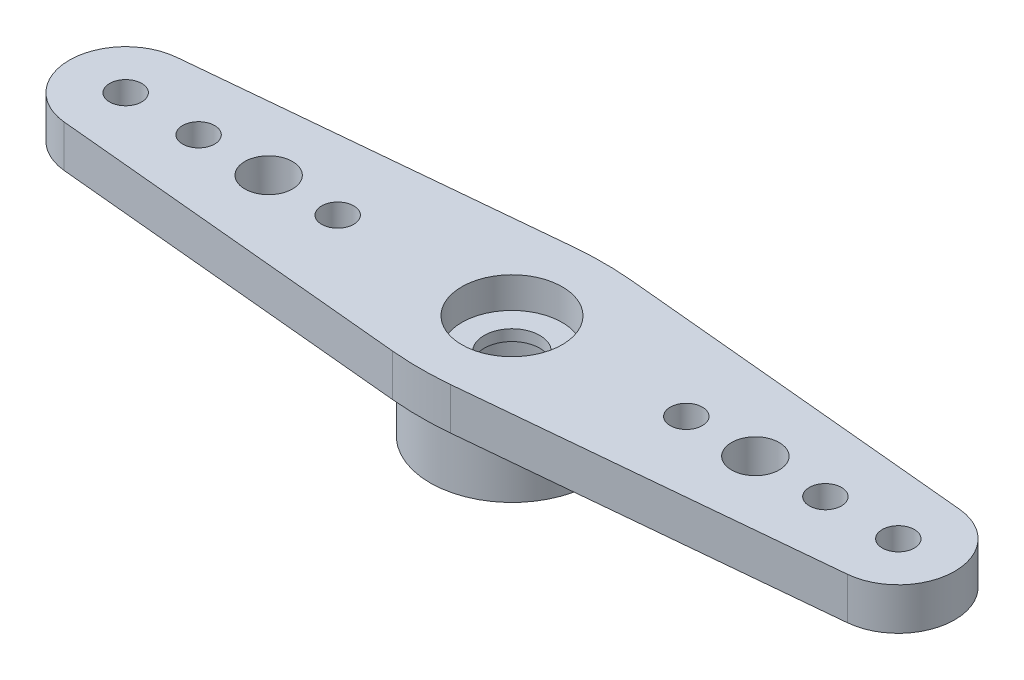
from build123d import *

# Parameters (mm, degrees)
SKETCH1_R           = 3.3655
SKETCH1_R_2         = 2.2352
BOSS_EXTRUDE1_DEPTH = 2.54
SKETCH2_R           = 0.6604
SKETCH2_R_2         = 2.31775
SKETCH2_R_3         = 3.3655
SKETCH2_R_4         = 2.2352
SKETCH2_R_5         = 1.143
BOSS_EXTRUDE2_DEPTH = 1.7272
FILLET1_R           = 12.7
SKETCH3_R           = 2.06375
SKETCH3_R_2         = 1.143
CUT_EXTRUDE1_DEPTH  = 1.27
SKETCH8_R           = 0.98
CUT_EXTRUDE4_DEPTH  = 20.062316393


with BuildPart() as part:
    # Sketch1 → Boss-Extrude1 (new body)
    with BuildSketch(Plane(origin=(0, 0, 0), x_dir=(1, 0, 0), z_dir=(0, 1, 0))):
        with Locations(Location((0, 0, 0), (0, 0, 270))):
            Circle(SKETCH1_R)
        with Locations(Location((0, 0, 0), (0, 0, 270))):
            Circle(SKETCH1_R_2, mode=Mode.SUBTRACT)
    extrude(amount=BOSS_EXTRUDE1_DEPTH)

    # Sketch2 → Boss-Extrude2 (add)
    with BuildSketch(Plane(origin=(0, 2.54, 0), x_dir=(1, 0, 0), z_dir=(0, 1, 0))):
        with BuildLine():
            ThreePointArc((-0.713521748, -3.755518873), (-3.8227, 0), (-0.713521748, 3.755518873))
            Line((-0.713521748, 3.755518873), (-16.092265178, 2.307544345))
            ThreePointArc((-16.092265178, 2.307544345), (-14.314807913, 1.713991165), (-13.55725, 0))
            ThreePointArc((-13.55725, 0), (-14.314807913, -1.713991165), (-16.092265178, -2.307544345))
            Line((-16.092265178, -2.307544345), (-0.713521748, -3.755518873))
        make_face()
        with Locations(Location((-12.8778, 0, 0), (0, 0, 270))):
            Circle(SKETCH2_R, mode=Mode.SUBTRACT)
        with Locations(Location((-9.8806, 0, 0), (0, 0, 270))):
            Circle(SKETCH2_R, mode=Mode.SUBTRACT)
        with Locations(Location((-7.1628, 0, 0), (0, 0, 270))):
            Circle(SKETCH2_R, mode=Mode.SUBTRACT)
        with Locations((-15.875, 0)):
            Circle(SKETCH2_R_2)
        with Locations(Location((-15.875, 0, 0), (0, 0, 270))):
            Circle(SKETCH2_R, mode=Mode.SUBTRACT)
        with BuildLine():
            Line((16.092265178, 2.307544345), (0.713521748, 3.755518873))
            ThreePointArc((0.713521748, 3.755518873), (2.944538578, 2.437771083), (3.8227, 0))
            ThreePointArc((3.8227, 0), (2.944538578, -2.437771083), (0.713521748, -3.755518873))
            Line((0.713521748, -3.755518873), (16.092265178, -2.307544345))
            ThreePointArc((16.092265178, -2.307544345), (13.55725, 0), (16.092265178, 2.307544345))
        make_face()
        with Locations(Location((7.1628, 0, 0), (0, 0, 270))):
            Circle(SKETCH2_R, mode=Mode.SUBTRACT)
        with Locations(Location((9.8806, 0, 0), (0, 0, 270))):
            Circle(SKETCH2_R, mode=Mode.SUBTRACT)
        with Locations(Location((12.8778, 0, 0), (0, 0, 270))):
            Circle(SKETCH2_R, mode=Mode.SUBTRACT)
        with Locations((15.875, 0)):
            Circle(SKETCH2_R_2)
        with Locations(Location((15.875, 0, 0), (0, 0, 270))):
            Circle(SKETCH2_R, mode=Mode.SUBTRACT)
        with BuildLine():
            Line((0.713521748, 3.755518873), (0, 3.8227))
            Line((0, 3.8227), (-0.713521748, 3.755518873))
            ThreePointArc((-0.713521748, 3.755518873), (-3.8227, 0), (-0.713521748, -3.755518873))
            Line((-0.713521748, -3.755518873), (0, -3.8227))
            Line((0, -3.8227), (0.713521748, -3.755518873))
            ThreePointArc((0.713521748, -3.755518873), (2.944538578, -2.437771083), (3.8227, 0))
            ThreePointArc((3.8227, 0), (2.944538578, 2.437771083), (0.713521748, 3.755518873))
        make_face()
        with Locations(Location((0, 0, 0), (0, 0, 270))):
            Circle(SKETCH2_R_3, mode=Mode.SUBTRACT)
        with Locations(Location((0, 0, 0), (0, 0, 270))):
            Circle(SKETCH2_R_3)
        with Locations(Location((0, 0, 0), (0, 0, 270))):
            Circle(SKETCH2_R_4, mode=Mode.SUBTRACT)
        with Locations(Location((0, 0, 0), (0, 0, 270))):
            Circle(SKETCH2_R_4)
        with Locations(Location((0, 0, 0), (0, 0, 270))):
            Circle(SKETCH2_R_5, mode=Mode.SUBTRACT)
    extrude(amount=BOSS_EXTRUDE2_DEPTH)

    # Fillet1
    fillet1_edges = [part.edges().sort_by_distance(p)[0] for p in [
        (0, 3.4036, -3.8227),
        (0, 3.4036, 3.8227),
    ]]
    fillet(fillet1_edges, radius=FILLET1_R)

    # Sketch3 → Cut-Extrude1 (cut)
    with BuildSketch(Plane(origin=(0, 4.2672, 0), x_dir=(1, 0, 0), z_dir=(0, 1, 0))):
        with Locations(Location((0, 0, 0), (0, 0, 270))):
            Circle(SKETCH3_R)
        with Locations(Location((0, 0, 0), (0, 0, 270))):
            Circle(SKETCH3_R_2, mode=Mode.SUBTRACT)
    extrude(amount=-CUT_EXTRUDE1_DEPTH, mode=Mode.SUBTRACT)

    # Sketch8 → Cut-Extrude4 (cut, through all)
    with BuildSketch(Plane(origin=(0, 4.2672, 0), x_dir=(1, 0, 0), z_dir=(0, 1, 0))):
        with Locations(Location((10, 0, 0), (0, 0, 270))):
            Circle(SKETCH8_R)
        with Locations(Location((-10, 0, 0), (0, 0, 270))):
            Circle(SKETCH8_R)
    extrude(amount=-CUT_EXTRUDE4_DEPTH, mode=Mode.SUBTRACT)


solid = part.part
